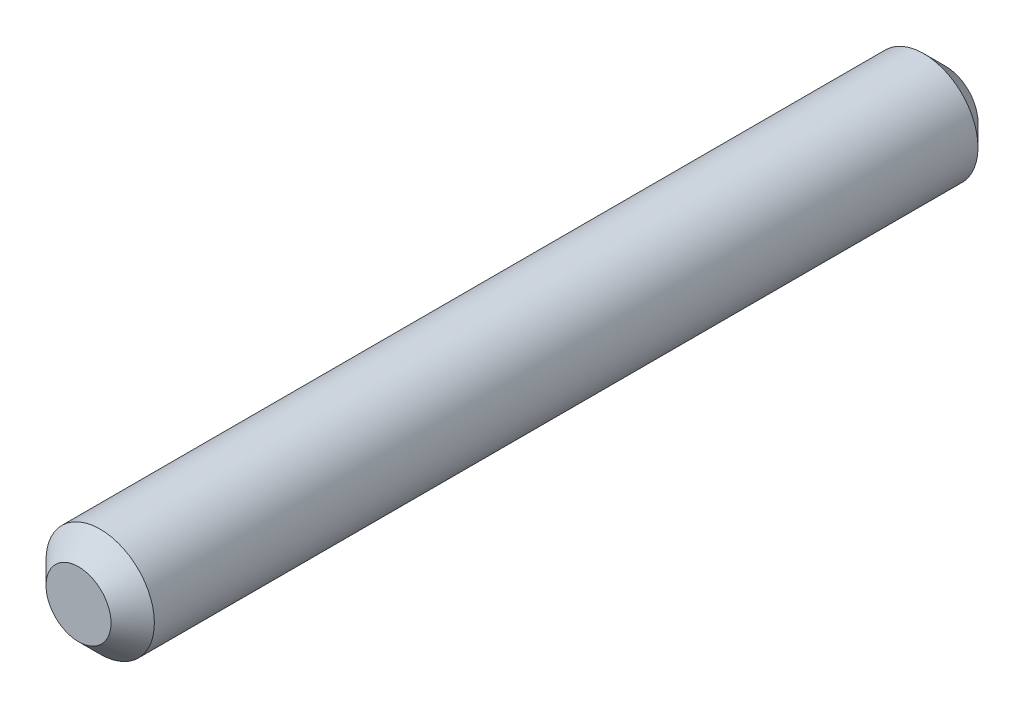
from build123d import *

# Parameters (mm, degrees)
SKETCH3_R           = 3.175
BOSS_EXTRUDE1_DEPTH = 50.8
CHAMFER1_SIZE       = 1.27


with BuildPart() as part:
    # Sketch3 → Boss-Extrude1 (new body)
    with BuildSketch(Plane.XY):
        Circle(SKETCH3_R)
    extrude(amount=BOSS_EXTRUDE1_DEPTH)

    # Chamfer1
    chamfer1_edges = [part.edges().sort_by_distance(p)[0] for p in [
        (-3.175, 0, 0),
        (-3.175, 0, 50.8),
    ]]
    chamfer(chamfer1_edges, length=CHAMFER1_SIZE)


solid = part.part
